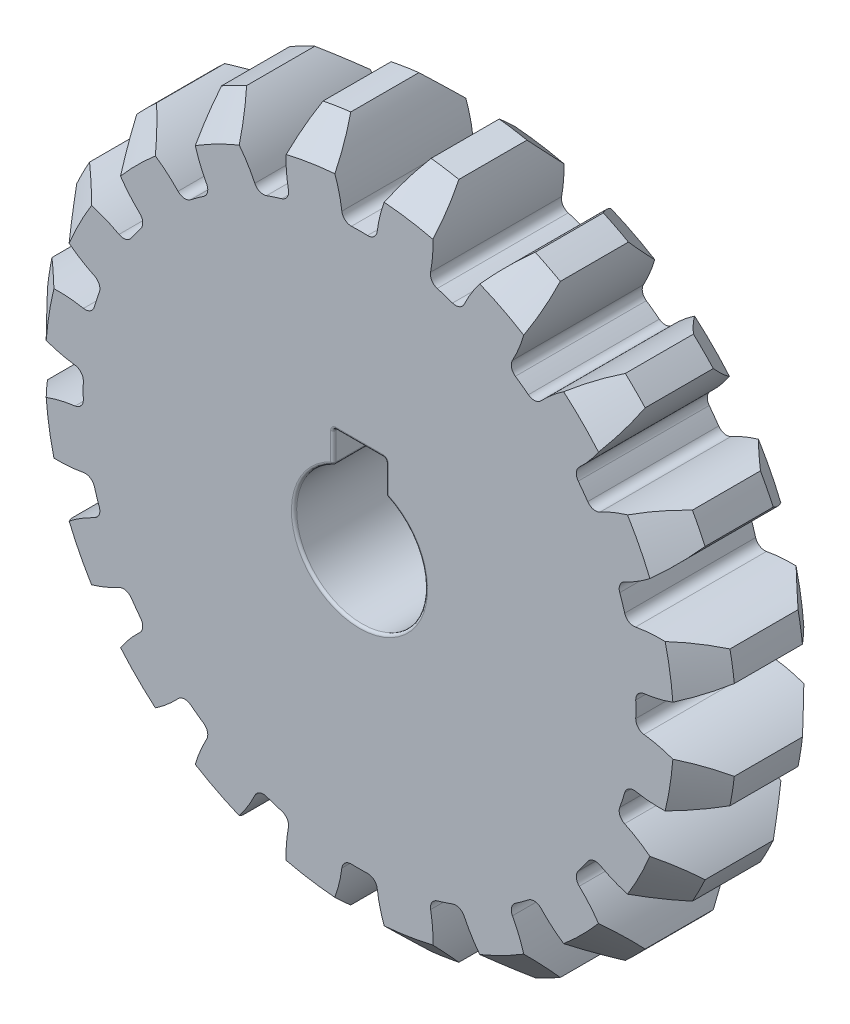
from build123d import *

# Parameters (mm, degrees)
SKETCH1_R                = 26.4
BOSS_EXTRUDE1_DEPTH      = 5
CUT_EXTRUDE1_DEPTH       = 6
FILLET1_R                = 0.72
CHAMFER1_SIZE            = 2.4
CIRPATTERN1_COUNT        = 20
FILLET1_OF_CIRPATTERN1_R = 0.72
CUT_EXTRUDE2_DEPTH       = 11.0000001
FILLET2_R                = 0.2


with BuildPart() as part:
    # Sketch1 → Boss-Extrude1 (new body, symmetric)
    with BuildSketch(Plane.XY):
        Circle(SKETCH1_R)
    extrude(amount=BOSS_EXTRUDE1_DEPTH, both=True)

    # Sketch2 → Cut-Extrude1 (cut, symmetric)
    with BuildSketch(Plane.XY):
        with BuildLine():
            ThreePointArc((3.066453718, 26.22130549), (1.825003706, 23.762296538), (1.287105373, 21.060706535))
            ThreePointArc((1.287105373, 21.060706535), (0, 21.1), (-1.287105373, 21.060706535))
            ThreePointArc((-1.287105373, 21.060706535), (-1.825003706, 23.762296538), (-3.066453718, 26.22130549))
            ThreePointArc((-3.066453718, 26.22130549), (0, 26.4), (3.066453718, 26.22130549))
        make_face()
    cut_extrude1 = extrude(amount=CUT_EXTRUDE1_DEPTH, both=True, mode=Mode.SUBTRACT)

    # Fillet1
    fillet1_edges = [part.edges().sort_by_distance(p)[0] for p in [
        (1.287105373, 21.060706535, 0),
        (-1.287105373, 21.060706535, 0),
    ]]
    fillet(fillet1_edges, radius=FILLET1_R)

    # Chamfer1
    chamfer1_edges = [part.edges().sort_by_distance(p)[0] for p in [
        (0, -26.4, -5),
        (0, -26.4, 5),
    ]]
    chamfer(chamfer1_edges, length=CHAMFER1_SIZE)

    # CirPattern1: Cut-Extrude1 ×20 about axis
    cirpattern1_axis = Axis((0, 0, 0), (0, 0, 1))
    for i in range(1, CIRPATTERN1_COUNT):
        add(cut_extrude1.rotate(cirpattern1_axis, i * 360 / CIRPATTERN1_COUNT), mode=Mode.SUBTRACT)

    # Fillet1 of CirPattern1
    fillet1_of_cirpattern1_edges = [part.edges().sort_by_distance(p)[0] for p in [
        (-5.284006281, 20.427659622, 0),
        (-7.732226185, 19.632184754, 0),
        (-11.337882584, 17.795011057, 0),
        (-13.420462824, 16.281927944, 0),
        (-16.281927944, 13.420462824, 0),
        (-17.795011057, 11.337882584, 0),
        (-19.632184754, 7.732226185, 0),
        (-20.427659622, 5.284006281, 0),
        (-21.060706535, 1.287105373, 0),
        (-21.060706535, -1.287105373, 0),
        (-20.427659622, -5.284006281, 0),
        (-19.632184754, -7.732226185, 0),
        (-17.795011057, -11.337882584, 0),
        (-16.281927944, -13.420462824, 0),
        (-13.420462824, -16.281927944, 0),
        (-11.337882584, -17.795011057, 0),
        (-7.732226185, -19.632184754, 0),
        (-5.284006281, -20.427659622, 0),
        (-1.287105373, -21.060706535, 0),
        (1.287105373, -21.060706535, 0),
        (5.284006281, -20.427659622, 0),
        (7.732226185, -19.632184754, 0),
        (11.337882584, -17.795011057, 0),
        (13.420462824, -16.281927944, 0),
        (16.281927944, -13.420462824, 0),
        (17.795011057, -11.337882584, 0),
        (19.632184754, -7.732226185, 0),
        (20.427659622, -5.284006281, 0),
        (21.060706535, -1.287105373, 0),
        (21.060706535, 1.287105373, 0),
        (20.427659622, 5.284006281, 0),
        (19.632184754, 7.732226185, 0),
        (17.795011057, 11.337882584, 0),
        (16.281927944, 13.420462824, 0),
        (13.420462824, 16.281927944, 0),
        (11.337882584, 17.795011057, 0),
        (7.732226185, 19.632184754, 0),
        (5.284006281, 20.427659622, 0),
    ]]
    fillet(fillet1_of_cirpattern1_edges, radius=FILLET1_OF_CIRPATTERN1_R)

    # Sketch3 → Cut-Extrude2 (cut, through all)
    with BuildSketch(Plane.XY.offset(5)):
        with BuildLine():
            Line((-2, 4.582575695), (-2, 7))
            Line((-2, 7), (2, 7))
            Line((2, 7), (2, 4.582575695))
            ThreePointArc((2, 4.582575695), (0, -5), (-2, 4.582575695))
        make_face()
    extrude(amount=-CUT_EXTRUDE2_DEPTH, mode=Mode.SUBTRACT)

    # Fillet2
    fillet2_edges = [part.edges().sort_by_distance(p)[0] for p in [
        (0, -5, -5),
        (2, 4.582575695, 0),
        (-2, 5.791287847, -5),
        (-2, 4.582575695, 0),
        (0, 7, -5),
        (-2, 7, 0),
        (2, 5.791287847, -5),
        (2, 7, 0),
        (0, -5, 5),
        (2, 5.791287847, 5),
        (0, 7, 5),
        (-2, 5.791287847, 5),
    ]]
    fillet(fillet2_edges, radius=FILLET2_R)


solid = part.part
